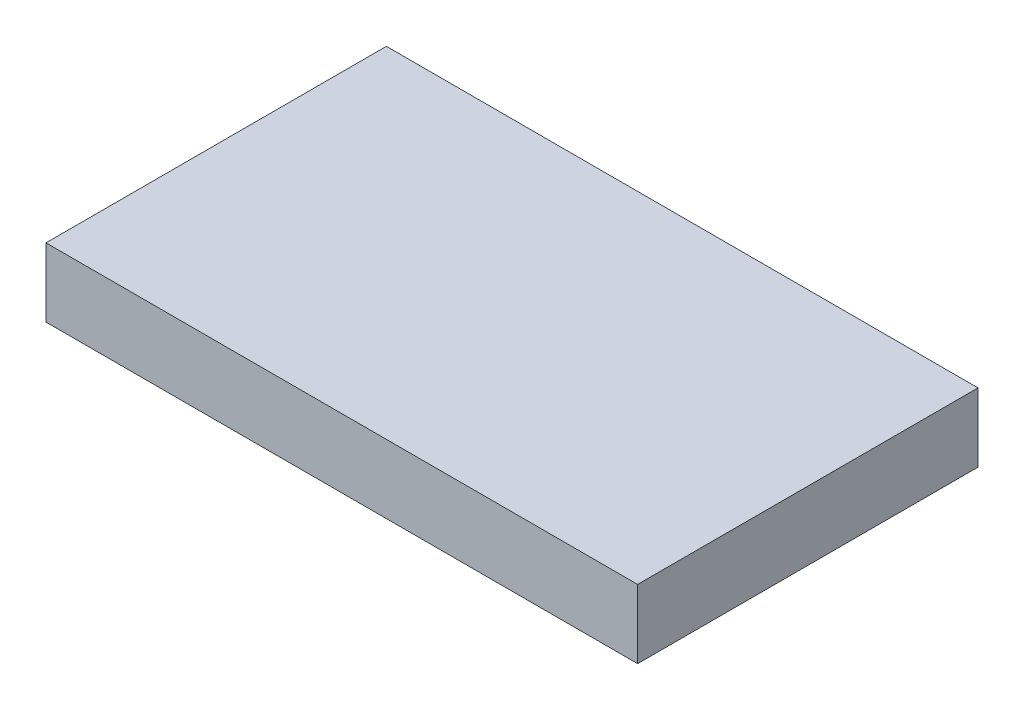
from build123d import *

# Parameters (mm, degrees)
SKETCH1_W           = 86.17367748
SKETCH1_H           = 49.579376084
BOSS_EXTRUDE1_DEPTH = 10


with BuildPart() as part:
    # Sketch1 → Boss-Extrude1 (new body)
    with BuildSketch(Plane(origin=(0, 0, 0), x_dir=(1, 0, 0), z_dir=(0, 1, 0))):
        with Locations((-6.492537344, 17.470827763)):
            Rectangle(SKETCH1_W, SKETCH1_H)
    extrude(amount=BOSS_EXTRUDE1_DEPTH)


solid = part.part
